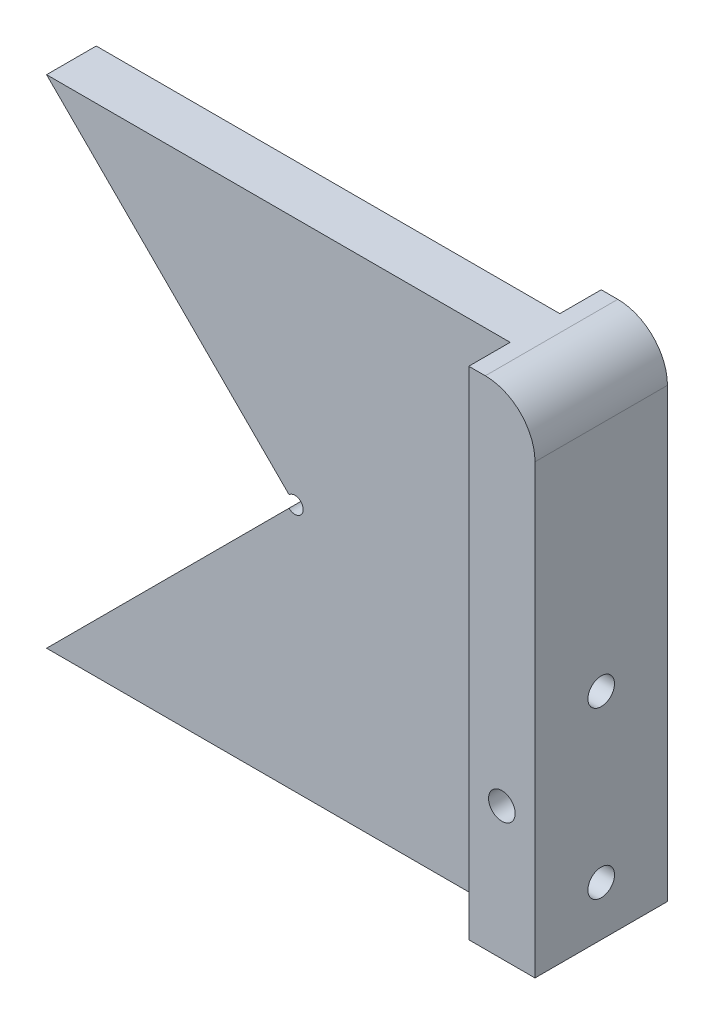
from build123d import *

# Parameters (mm, degrees)
BOSS_EXTRUDE1_DEPTH         = 4.7625
SKETCH2_R                   = 1.5875
CUT_EXTRUDE1_DEPTH          = 10.525
SKETCH3_W                   = 25.4
SKETCH3_H                   = 95.25
BOSS_EXTRUDE2_DEPTH         = 12.7
FILLET1_R                   = 9.525
F_1_4_20_TAPPED_HOLE1_D     = 5.1054
F_1_4_20_TAPPED_HOLE1_DEPTH = 15.875
F_1_4_20_TAPPED_HOLE1_TIP   = 1.533816902
F_1_4_20_TAPPED_HOLE2_D     = 5.1054


with BuildPart() as part:
    # Sketch1 → Boss-Extrude1 (new body, symmetric)
    with BuildSketch(Plane.XY):
        Polygon((-47.625, 47.625), (41.275, 47.625), (41.275, -47.625), (-47.625, -47.625), (0, 0), align=None)
    extrude(amount=BOSS_EXTRUDE1_DEPTH, both=True)

    # Sketch2 → Cut-Extrude1 (cut, through all)
    with BuildSketch(Plane.XY.offset(4.7625)):
        Circle(SKETCH2_R)
    extrude(amount=-CUT_EXTRUDE1_DEPTH, mode=Mode.SUBTRACT)

    # Sketch3 → Boss-Extrude2 (add)
    with BuildSketch(Plane(origin=(41.275, 0, 0), x_dir=(0, 0, -1), z_dir=(1, 0, 0))):
        Rectangle(SKETCH3_W, SKETCH3_H)
    extrude(amount=BOSS_EXTRUDE2_DEPTH)

    # Fillet1
    fillet1_edges = [part.edges().sort_by_distance(p)[0] for p in [
        (53.975, 47.625, 0),
    ]]
    fillet(fillet1_edges, radius=FILLET1_R)

    # 1/4-20 Tapped Hole1
    with Locations(Plane(origin=(53.975, 0, 0), x_dir=(0, 0, -1), z_dir=(1, 0, 0))):
        with Locations((0, -38.1), (0, -6.35)):
            Hole(F_1_4_20_TAPPED_HOLE1_D / 2, depth=F_1_4_20_TAPPED_HOLE1_DEPTH)
            with Locations((0, 0, -(F_1_4_20_TAPPED_HOLE1_DEPTH + F_1_4_20_TAPPED_HOLE1_TIP / 2))):  # 118° drill point
                Cone(0, F_1_4_20_TAPPED_HOLE1_D / 2, F_1_4_20_TAPPED_HOLE1_TIP, mode=Mode.SUBTRACT)

    # 1/4-20 Tapped Hole2 (through all)
    with Locations(Plane.XY.offset(12.7)):
        with Locations((47.625, -22.225)):
            Hole(F_1_4_20_TAPPED_HOLE2_D / 2)


solid = part.part
